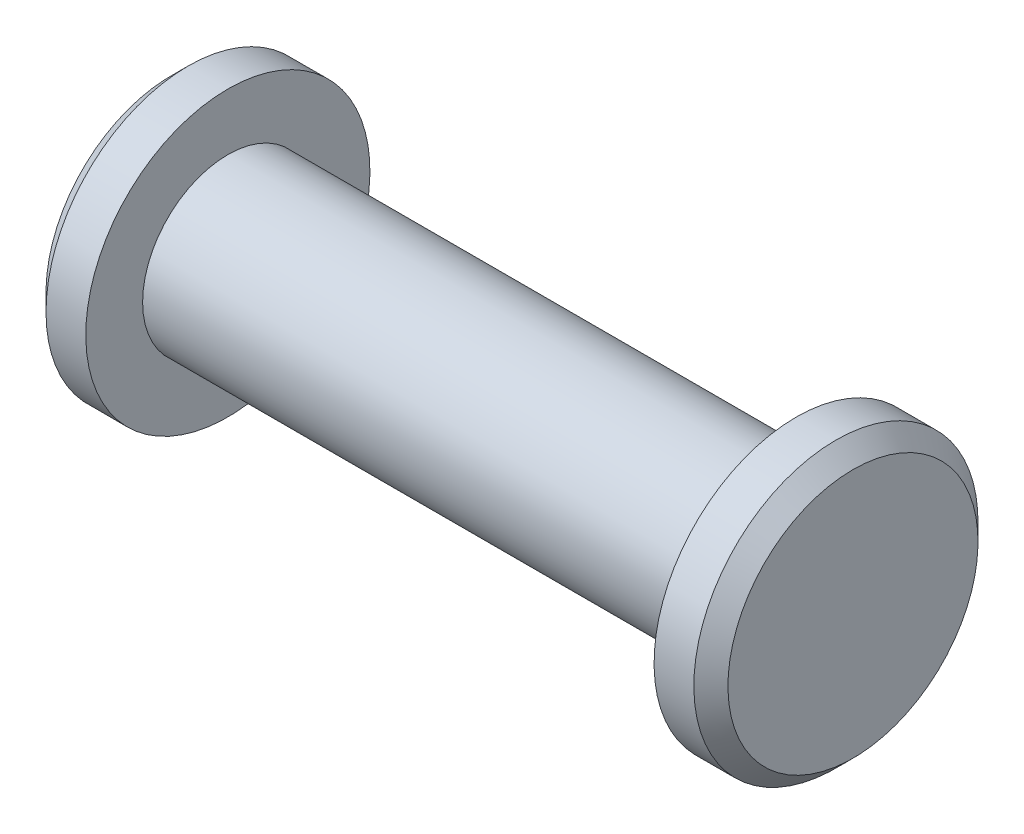
from build123d import *

# Parameters (mm, degrees)
CHAMFER1_SIZE = 3


with BuildPart() as part:
    # Sketch1 → Revolve1 (revolve)
    with BuildSketch(Plane.XY):
        Polygon((0, 0), (-120, 0), (-120, 25), (-110, 25), (-110, 15), (-10, 15), (-10, 25), (0, 25), align=None)
    revolve(axis=Axis((0, 0, 0), (-1, 0, 0)))

    # Chamfer1
    chamfer1_edges = [part.edges().sort_by_distance(p)[0] for p in [
        (0, -25, 0),
        (-120, -25, 0),
    ]]
    chamfer(chamfer1_edges, length=CHAMFER1_SIZE)


solid = part.part
